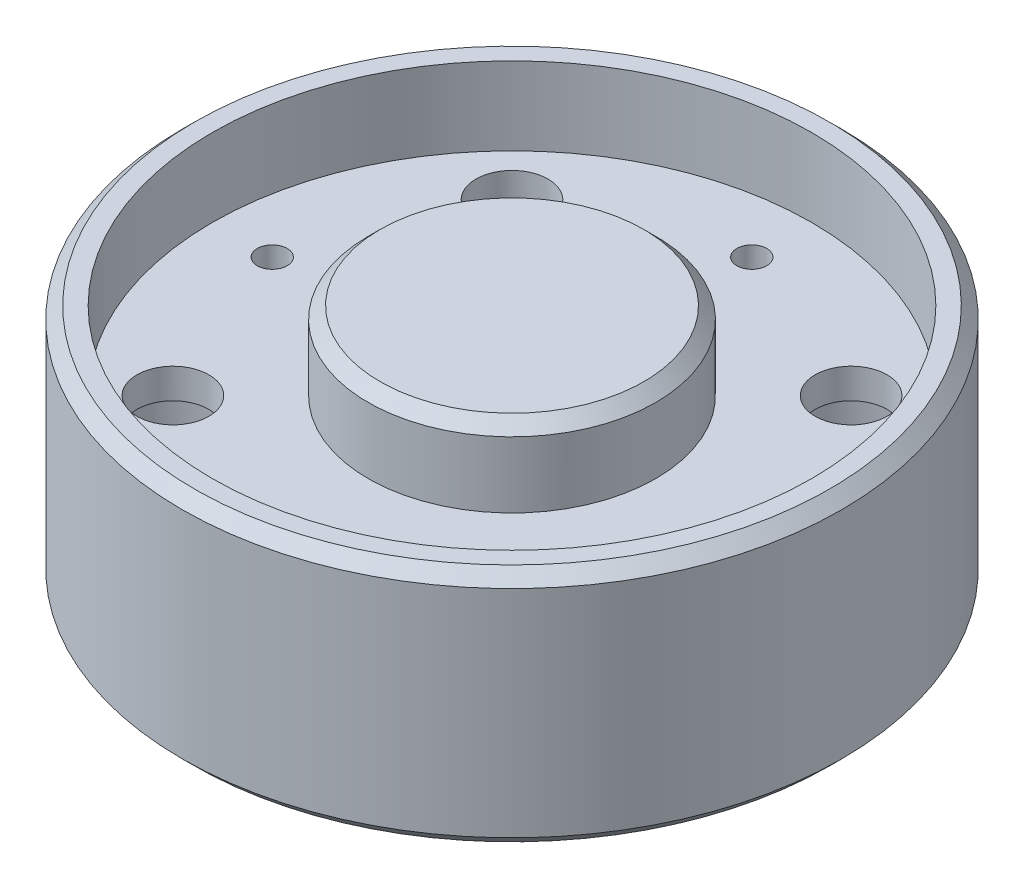
from build123d import *

# Parameters (mm, degrees)
SKETCH2_R               = 3
CUT_EXTRUDE2_DEPTH      = 21
CUT_EXTRUDE2_DEPTH_BACK = 1
SKETCH3_R               = 5.5
CUT_EXTRUDE3_DEPTH      = 11
CUT_EXTRUDE4_REACH      = 16.5
SKETCH4_R               = 1.25
CHAMFER1_SIZE           = 1


with BuildPart() as part:
    # Sketch1 → Revolve1 (revolve)
    with BuildSketch(Plane.XY):
        Polygon((27.5, 0), (27.5, 20), (25, 20), (25, 13.5), (12, 13.5), (12, 20), (0, 20), (0, 5.5), (22.4, 5.5), (22.4, 0), align=None)
    revolve(axis=Axis((0, -626.687351978, 0), (0, 1, 0)))

    # Sketch2 → Cut-Extrude2 (cut, two sides)
    with BuildSketch(Plane(origin=(0, 0, 0), x_dir=(1, 0, 0), z_dir=(0, 1, 0))) as cut_extrude2_sk:
        with Locations((-14.142135624, 14.142135624)):
            Circle(SKETCH2_R)
        with Locations((14.142135624, 14.142135624)):
            Circle(SKETCH2_R)
        with Locations((14.142135624, -14.142135624)):
            Circle(SKETCH2_R)
        with Locations((-14.142135624, -14.142135624)):
            Circle(SKETCH2_R)
    extrude(amount=CUT_EXTRUDE2_DEPTH, mode=Mode.SUBTRACT)
    extrude(cut_extrude2_sk.sketch, amount=-CUT_EXTRUDE2_DEPTH_BACK, mode=Mode.SUBTRACT)

    # Sketch3 → Cut-Extrude3 (cut)
    with BuildSketch(Plane.XZ):
        with Locations((-14.142135624, 14.142135624)):
            Circle(SKETCH3_R)
        with Locations((14.142135624, 14.142135624)):
            Circle(SKETCH3_R)
        with Locations((14.142135624, -14.142135624)):
            Circle(SKETCH3_R)
        with Locations((-14.142135624, -14.142135624)):
            Circle(SKETCH3_R)
    extrude(amount=-CUT_EXTRUDE3_DEPTH, mode=Mode.SUBTRACT)

    # Sketch4 → Cut-Extrude4 (cut, up to next)
    with BuildSketch(Plane.XZ.offset(-5.5), mode=Mode.PRIVATE) as cut_extrude4_sk1:
        with Locations((0, 20)):
            Circle(SKETCH4_R)
    cut_extrude4_tool1 = extrude(cut_extrude4_sk1.sketch, amount=-CUT_EXTRUDE4_REACH, mode=Mode.PRIVATE) & part.part
    add(cut_extrude4_tool1.solids().sort_by_distance((0, 5.5, 20))[0], mode=Mode.SUBTRACT)
    # Sketch4 → Cut-Extrude4 (cut, up to next)
    with BuildSketch(Plane.XZ.offset(-5.5), mode=Mode.PRIVATE) as cut_extrude4_sk2:
        with Locations((-20, 0)):
            Circle(SKETCH4_R)
    cut_extrude4_tool2 = extrude(cut_extrude4_sk2.sketch, amount=-CUT_EXTRUDE4_REACH, mode=Mode.PRIVATE) & part.part
    add(cut_extrude4_tool2.solids().sort_by_distance((-20, 5.5, 0))[0], mode=Mode.SUBTRACT)
    # Sketch4 → Cut-Extrude4 (cut, up to next)
    with BuildSketch(Plane.XZ.offset(-5.5), mode=Mode.PRIVATE) as cut_extrude4_sk3:
        with Locations((0, -20)):
            Circle(SKETCH4_R)
    cut_extrude4_tool3 = extrude(cut_extrude4_sk3.sketch, amount=-CUT_EXTRUDE4_REACH, mode=Mode.PRIVATE) & part.part
    add(cut_extrude4_tool3.solids().sort_by_distance((0, 5.5, -20))[0], mode=Mode.SUBTRACT)
    # Sketch4 → Cut-Extrude4 (cut, up to next)
    with BuildSketch(Plane.XZ.offset(-5.5), mode=Mode.PRIVATE) as cut_extrude4_sk4:
        with Locations((20, 0)):
            Circle(SKETCH4_R)
    cut_extrude4_tool4 = extrude(cut_extrude4_sk4.sketch, amount=-CUT_EXTRUDE4_REACH, mode=Mode.PRIVATE) & part.part
    add(cut_extrude4_tool4.solids().sort_by_distance((20, 5.5, 0))[0], mode=Mode.SUBTRACT)

    # Chamfer1
    chamfer1_edges = [part.edges().sort_by_distance(p)[0] for p in [
        (-12, 20, 0),
        (-27.5, 0, 0),
        (-27.5, 20, 0),
    ]]
    chamfer(chamfer1_edges, length=CHAMFER1_SIZE)


solid = part.part
